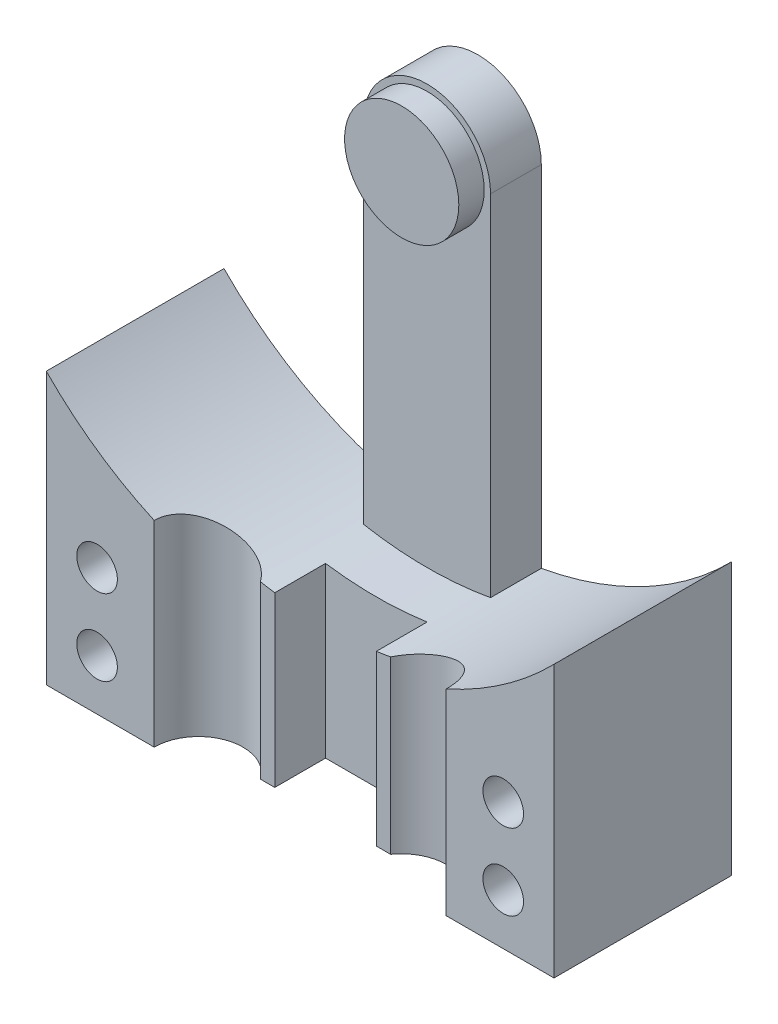
from build123d import *

# Parameters (mm, degrees)
BOSS_EXTRUDE1_DEPTH = 7
BOSS_EXTRUDE2_DEPTH = 2
BOSS_EXTRUDE3_START = 2
SKETCH3_R           = 2.25
BOSS_EXTRUDE3_DEPTH = 1
SKETCH4_R           = 0.8
SCREW_HOLES_DEPTH   = 8
CABLE_START         = -20.5
SKETCH6_R           = 1.75
CABLE_TUBES_DEPTH   = 18.5
WIRE_START          = -20.5
WIRE_CANALS_DEPTH   = 7.5


with BuildPart() as part:
    # Sketch1 → Boss-Extrude1 (new body)
    with BuildSketch(Plane.XY):
        with BuildLine():
            ThreePointArc((10, -9.797958971), (0, -14), (-10, -9.797958971))
            Line((-10, -9.797958971), (-10, -20.5))
            Line((-10, -20.5), (10, -20.5))
            Line((10, -20.5), (10, -9.797958971))
        make_face()
    extrude(amount=BOSS_EXTRUDE1_DEPTH)

    # Sketch2 → Boss-Extrude2 (add)
    with BuildSketch(Plane.XY):
        with BuildLine():
            Line((-2.5, 0), (-2.5, -20.5))
            Line((-2.5, -20.5), (2.5, -20.5))
            Line((2.5, -20.5), (2.5, 0))
            ThreePointArc((2.5, 0), (0, 2.5), (-2.5, 0))
        make_face()
    extrude(amount=BOSS_EXTRUDE2_DEPTH)

    # Sketch3 → Boss-Extrude3 (add)
    with BuildSketch(Plane.XY.offset(BOSS_EXTRUDE3_START)):
        Circle(SKETCH3_R)
    extrude(amount=BOSS_EXTRUDE3_DEPTH)

    # Sketch4 → Screw Holes (cut, through all)
    with BuildSketch(Plane.XY):
        with Locations((-8, -15.5)):
            Circle(SKETCH4_R)
        with Locations((8, -15.5)):
            Circle(SKETCH4_R)
        with Locations((-8, -18.5)):
            Circle(SKETCH4_R)
        with Locations((8, -18.5)):
            Circle(SKETCH4_R)
    extrude(amount=SCREW_HOLES_DEPTH, mode=Mode.SUBTRACT)

    # Sketch6 → Cable Tubes (cut)
    with BuildSketch(Plane(origin=(0, 0, 0), x_dir=(1, 0, 0), z_dir=(0, 1, 0)).offset(CABLE_START)):
        with Locations((-4, -7)):
            Circle(SKETCH6_R)
        with Locations((4, -7)):
            Circle(SKETCH6_R)
    extrude(amount=CABLE_TUBES_DEPTH, mode=Mode.SUBTRACT)

    # Sketch7 → Wire Canals (cut)
    with BuildSketch(Plane(origin=(0, 0, 0), x_dir=(1, 0, 0), z_dir=(0, 1, 0)).offset(WIRE_START)):
        Polygon((-3, -6), (-2, -6), (-2, -4), (2, -4), (2, -6), (3, -6), (3, -7), (-3, -7), align=None)
    extrude(amount=WIRE_CANALS_DEPTH, mode=Mode.SUBTRACT)


solid = part.part
